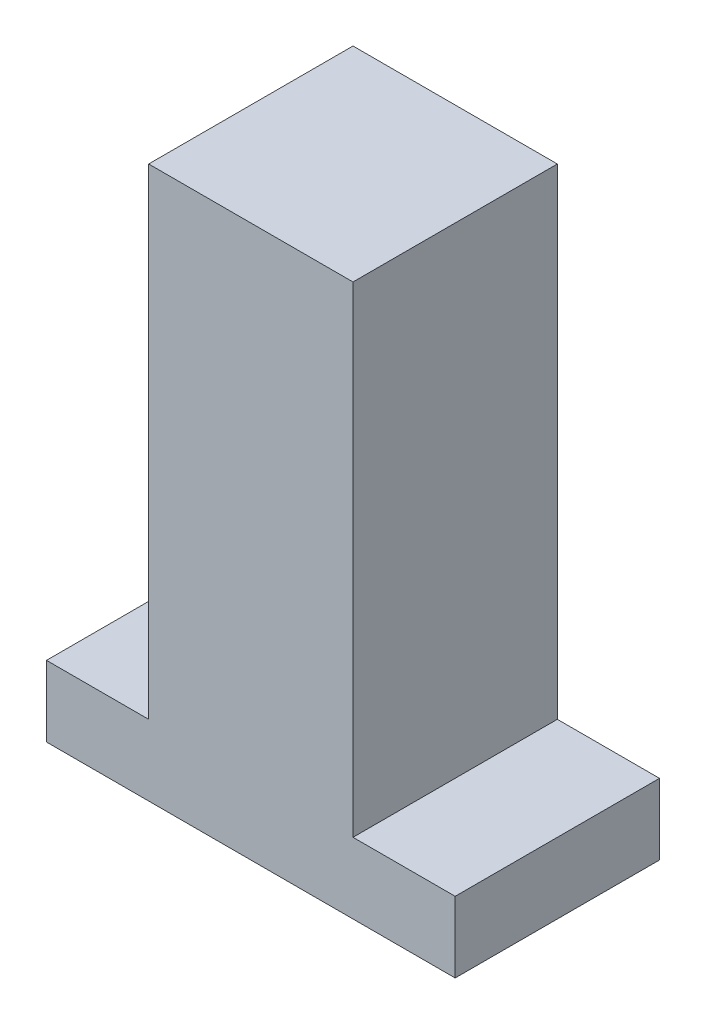
from build123d import *

# Parameters (mm, degrees)
BOSS_EXTRUDE1_DEPTH = 30


with BuildPart() as part:
    # Sketch1 → Boss-Extrude1 (new body)
    with BuildSketch(Plane.XY):
        Polygon((-15, -81), (0, -81), (30, -81), (45, -81), (45, -70.610451306), (30, -70.610451306), (30, 0), (0, 0), (0, -70.610451306), (-15, -70.610451306), align=None)
    extrude(amount=BOSS_EXTRUDE1_DEPTH)


solid = part.part
